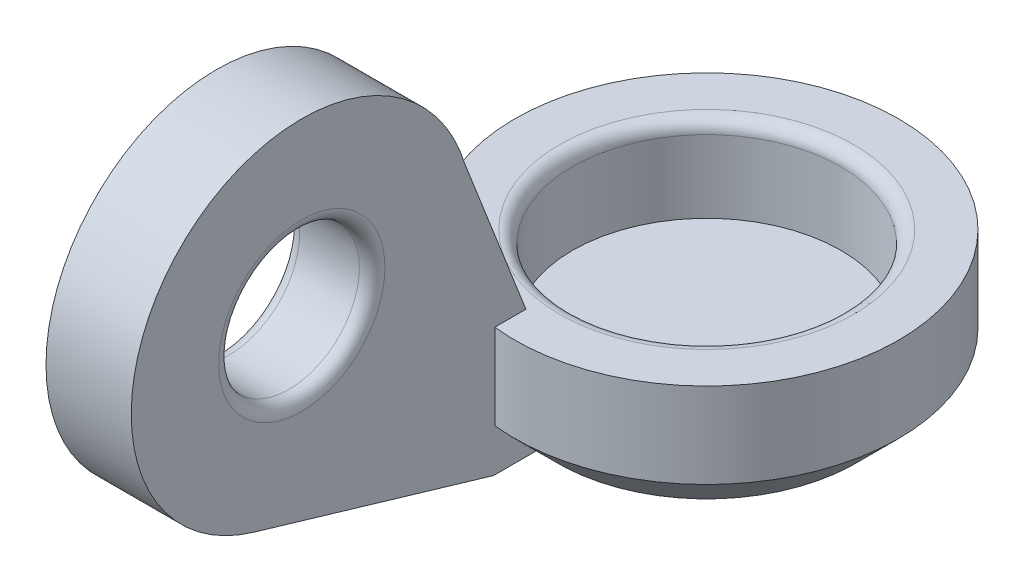
from build123d import *

# Parameters (mm, degrees)
SKETCH_6_R          = 4.5
EXTRUDE_4_DEPTH     = 3
SKETCH_7_R          = 3.15
CUT_EXTRUDE_4_DEPTH = 2
SKETCH_8_R          = 4
EXTRUDE_5_DEPTH     = 2
EXTRUDE_7_DEPTH     = 2
EXTRUDE_8_REACH     = 10
SKETCH_11_R         = 1.65
CUT_EXTRUDE_6_DEPTH = 2
CUT_EXTRUDE_7_REACH = 9
FILLET_1_R          = 0.3
FILLET_2_R          = 0.3
FILLET_3_R          = 0.3


with BuildPart() as part:
    # 草图6 → 凸台-拉伸4 (new body)
    with BuildSketch(Plane(origin=(0, 0, 0), x_dir=(1, 0, 0), z_dir=(0, 1, 0))):
        Circle(SKETCH_6_R)
    extrude(amount=-EXTRUDE_4_DEPTH)

    # 草图7 → 切除-拉伸4 (cut)
    with BuildSketch(Plane(origin=(0, 0, 0), x_dir=(1, 0, 0), z_dir=(0, 1, 0))):
        Circle(SKETCH_7_R)
    extrude(amount=-CUT_EXTRUDE_4_DEPTH, mode=Mode.SUBTRACT)

    # 草图15 → 切除-旋转2 (revolve, cut)
    with BuildSketch(Plane(origin=(0, 0, 0), x_dir=(0, 0, -1), z_dir=(1, 0, 0))):
        Polygon((4.5, -3), (4.5, -2), (3.5, -3), align=None)
    revolve(axis=Axis((0, 0, 0), (0, -1, 0)), mode=Mode.SUBTRACT)



with BuildPart() as body_2:
    # 草图8 → 凸台-拉伸5 (new body)
    with BuildSketch(Plane(origin=(-0.5, 0, 0), x_dir=(0, 0, -1), z_dir=(1, 0, 0))):
        with Locations((-9, 2.5)):
            Circle(SKETCH_8_R)
    extrude(amount=-EXTRUDE_5_DEPTH)


with BuildPart() as part_1:
    add(part.part)

    add(body_2.part)  # 凸台-拉伸7 merges body 2
    # 草图9 → 凸台-拉伸7 (add)
    with BuildSketch(Plane(origin=(-0.5, 0, 0), x_dir=(0, 0, -1), z_dir=(1, 0, 0))):
        Polygon((-4.5, -3), (-10.133083988, -1.336159626), (-5.152908316, 3.69564436), (-3.5, 0), (-3.5, -3), (-3.52896076, -3), align=None)
    extrude(amount=-EXTRUDE_7_DEPTH)

    # 草图16 → 凸台-拉伸8 (add, up to next)
    with BuildSketch(Plane(origin=(0, 0, 3.5), x_dir=(-1, 0, 0), z_dir=(0, 0, -1)), mode=Mode.PRIVATE) as extrude_8_sk1:
        Polygon((2.5, -3), (2.5, -2.198837366), (0.5, -2.955716811), (0.5, -3), align=None)
    extrude_8_tool1 = extrude(extrude_8_sk1.sketch, amount=EXTRUDE_8_REACH, mode=Mode.PRIVATE) - part_1.part
    add(extrude_8_tool1.solids().sort_by_distance((-1.798414, -2.732173, 3.5))[0])

    # 草图11 → 切除-拉伸6 (cut)
    with BuildSketch(Plane(origin=(-0.5, 0, 0), x_dir=(0, 0, -1), z_dir=(1, 0, 0))):
        with Locations((-9, 2.5)):
            Circle(SKETCH_11_R)
    extrude(amount=-CUT_EXTRUDE_6_DEPTH, mode=Mode.SUBTRACT)

    # 草图12 → 切除-拉伸7 (cut, up to next)
    with BuildSketch(Plane.ZY.offset(2.5), mode=Mode.PRIVATE) as cut_extrude_7_sk1:
        Polygon((3.5, 0), (3.741657387, 0), (5.175729917, 3.672586172), (5.152908316, 3.69564436), align=None)
    cut_extrude_7_tool1 = extrude(cut_extrude_7_sk1.sketch, amount=-CUT_EXTRUDE_7_REACH, mode=Mode.PRIVATE) & part_1.part
    add(cut_extrude_7_tool1.solids().sort_by_distance((-2.5, 1.373556, 4.196165))[0], mode=Mode.SUBTRACT)

    # 圆角1
    fillet_1_edges = [part_1.edges().sort_by_distance(p)[0] for p in [
        (-3.15, 0, 0),
    ]]
    fillet(fillet_1_edges, radius=FILLET_1_R)

    # 圆角2
    fillet_2_edges = [part_1.edges().sort_by_distance(p)[0] for p in [
        (-0.5, 2.5, 10.65),
    ]]
    fillet(fillet_2_edges, radius=FILLET_2_R)

    # 圆角3
    fillet_3_edges = [part_1.edges().sort_by_distance(p)[0] for p in [
        (-2.5, 2.5, 10.65),
    ]]
    fillet(fillet_3_edges, radius=FILLET_3_R)


solid = part_1.part
